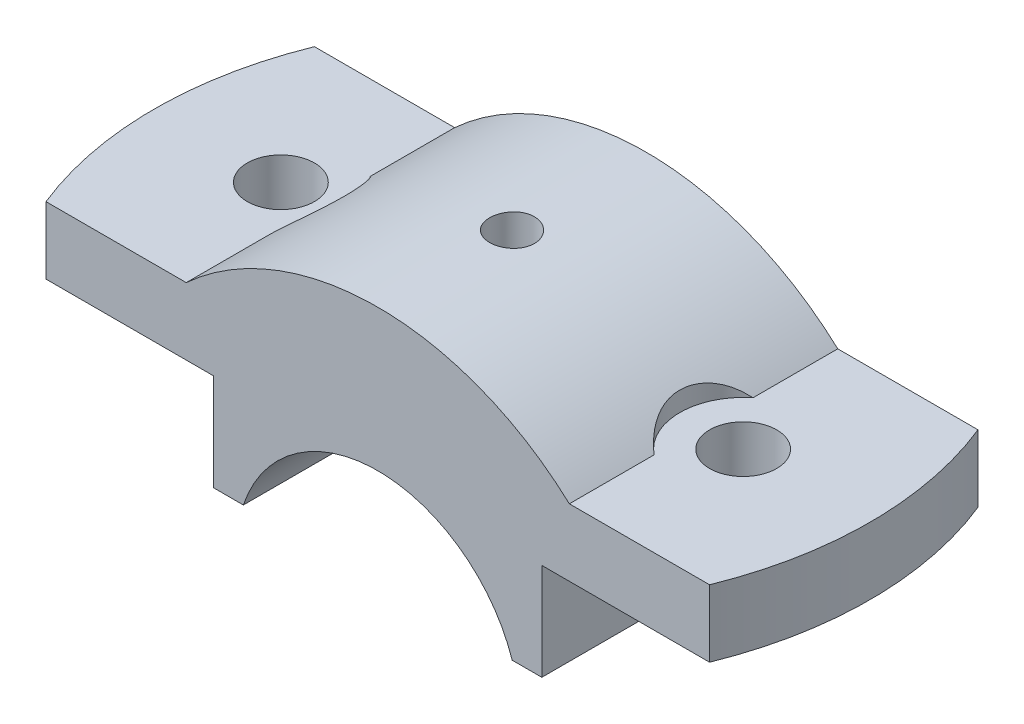
from build123d import *

# Parameters (mm, degrees)
BOSS_EXTRUDE1_DEPTH = 18
CUT_EXTRUDE1_DEPTH  = 9
CUT_EXTRUDE2_DEPTH  = 11


with BuildPart() as part:
    # Sketch1 → Boss-Extrude1 (new body, symmetric)
    with BuildSketch(Plane.XY):
        with BuildLine():
            Line((18.027756377, 6), (22, 6))
            Line((22, 6), (22, 19))
            Line((22, 19), (50, 19))
            Line((50, 19), (50, 28))
            Line((50, 28), (25.690465157, 28))
            ThreePointArc((25.690465157, 28), (0, 38), (-25.690465157, 28))
            Line((-25.690465157, 28), (-50, 28))
            Line((-50, 28), (-50, 19))
            Line((-50, 19), (-22, 19))
            Line((-22, 19), (-22, 6))
            Line((-22, 6), (-18.027756377, 6))
            ThreePointArc((-18.027756377, 6), (0, 19), (18.027756377, 6))
        make_face()
    extrude(amount=BOSS_EXTRUDE1_DEPTH, both=True)

    # Sketch2 → Cut-Extrude1 (cut)
    with BuildSketch(Plane(origin=(0, 28, 0), x_dir=(1, 0, 0), z_dir=(0, 1, 0))):
        with BuildLine():
            Line((-44.497190923, 18), (-50, 18))
            Line((-50, 18), (-50, -18))
            Line((-50, -18), (-44.497190923, -18))
            ThreePointArc((-44.497190923, -18), (-48, 0), (-44.497190923, 18))
        make_face()
    cut_extrude1 = extrude(amount=-CUT_EXTRUDE1_DEPTH, mode=Mode.SUBTRACT)

    # Sketch73 → Ø16.0mm Dowel Hole21 (revolve, cut)
    with BuildSketch(Plane(origin=(-31, 28, 0), x_dir=(0, 0, 1), z_dir=(1, 0, 0))):
        Polygon((0, 0), (0, 11.703872786), (4.5, 9), (4.5, 0), align=None)
    f_16_0mm_dowel_hole21 = revolve(axis=Axis((-31, 34.35, 0), (0, -1, 0)), mode=Mode.SUBTRACT)

    # 3DSketch2 → Cut-Extrude2 (cut, through all)
    with BuildSketch(Plane(origin=(-25.690465157, 28, 6.637683312), x_dir=(0, 0, -1), z_dir=(0, 1, 0))):
        with BuildLine():
            Line((0, 0), (13.275366625, 0))
            ThreePointArc((13.275366625, 0), (6.637683312, -3.190465157), (0, 0))
        make_face()
    cut_extrude2 = extrude(amount=CUT_EXTRUDE2_DEPTH, mode=Mode.SUBTRACT)

    # Mirror2: Ø16.0mm Dowel Hole21, Cut-Extrude2 across plane
    add(f_16_0mm_dowel_hole21.mirror(Plane(origin=(0, 0, 0), x_dir=(0, 0, 1), z_dir=(1, 0, 0))), mode=Mode.SUBTRACT)
    add(cut_extrude2.mirror(Plane(origin=(0, 0, 0), x_dir=(0, 0, 1), z_dir=(1, 0, 0))), mode=Mode.SUBTRACT)

    # Sketch85 → CBORE for M6 Hex Head Machine Screw4 (revolve, cut)
    with BuildSketch(Plane(origin=(0, 38, 0), x_dir=(0, 0, 1), z_dir=(1, 0, 0))):
        Polygon((0, 0), (0, 32), (2.5, 32), (2.5, 13.495), (2.995, 13), (3, 13), (3, 0), align=None)
    revolve(axis=Axis((0, 44.35, 0), (0, -1, 0)), mode=Mode.SUBTRACT)

    # Mirror4: Cut-Extrude1 across plane
    add(cut_extrude1.mirror(Plane(origin=(0, 0, 0), x_dir=(0, 0, 1), z_dir=(1, 0, 0))), mode=Mode.SUBTRACT)


solid = part.part
